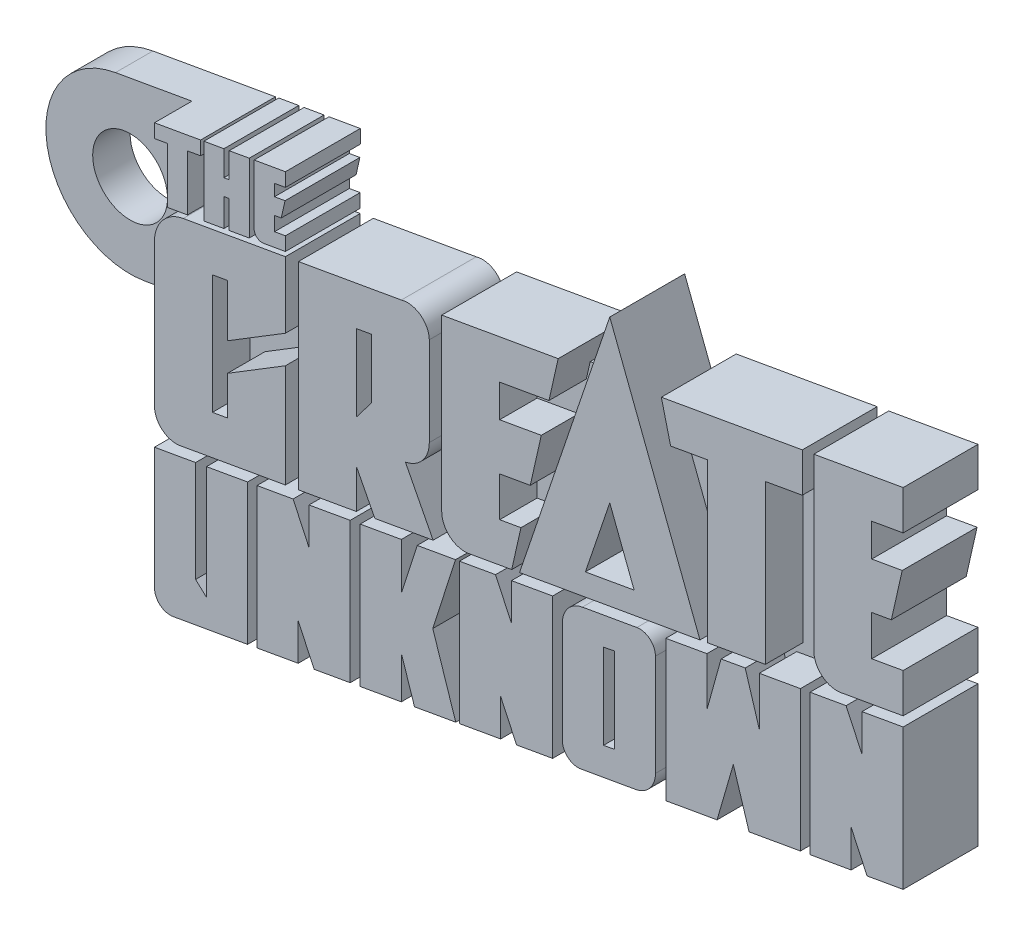
from build123d import *

# Parameters (mm, degrees)
BOSS_EXTRUDE1_DEPTH    = 2
BOSS_EXTRUDE1_2_DEPTH  = 2
BOSS_EXTRUDE1_3_DEPTH  = 2
BOSS_EXTRUDE1_4_DEPTH  = 2
BOSS_EXTRUDE1_5_DEPTH  = 2
BOSS_EXTRUDE1_6_DEPTH  = 2
BOSS_EXTRUDE1_7_DEPTH  = 2
BOSS_EXTRUDE1_8_DEPTH  = 2
BOSS_EXTRUDE1_9_DEPTH  = 2
BOSS_EXTRUDE1_10_DEPTH = 2
BOSS_EXTRUDE1_11_DEPTH = 2
BOSS_EXTRUDE1_12_DEPTH = 2
BOSS_EXTRUDE1_13_DEPTH = 2
BOSS_EXTRUDE1_14_DEPTH = 2
BOSS_EXTRUDE1_15_DEPTH = 2
BOSS_EXTRUDE1_16_DEPTH = 2
SKETCH3_R              = 2
BOSS_EXTRUDE2_DEPTH    = 2


with BuildPart() as part:
    # Sketch1 → Boss-Extrude1 (new body)
    with BuildSketch(Plane.XY):
        with BuildLine():
            Line((8.52687857, 18.63088909), (8.52687857, 11.115073474))
            Line((8.52687857, 11.115073474), (4.54411302, 10.41280445))
            ThreePointArc((4.54411302, 10.41280445), (3.854578969, 10.597564542), (3.552889466, 11.244539768))
            Line((3.552889466, 11.244539768), (3.552889466, 17.753840609))
            Line((3.552889466, 17.753840609), (5.74780863, 18.140864079))
            Line((5.74780863, 18.140864079), (5.74780863, 12.731665884))
            Line((5.74780863, 12.731665884), (6.331959407, 12.196171059))
            Line((6.331959407, 12.196171059), (6.331959407, 18.243865621))
            Line((6.331959407, 18.243865621), (8.52687857, 18.63088909))
        make_face()
    extrude(amount=BOSS_EXTRUDE1_DEPTH)



with BuildPart() as body_2:
    # Sketch1 → Boss-Extrude1 2 (new body)
    with BuildSketch(Plane.XY):
        Polygon((14.007807054, 12.081509045), (14.007807054, 19.597324661), (11.810238392, 19.209834014), (11.810238392, 17.233228675), (10.95855946, 19.05966004), (9.032205584, 18.719991877), (9.032205584, 11.204176261), (11.229774246, 11.591666908), (11.229774246, 13.568272247), (12.081453179, 11.741840883), align=None)
    extrude(amount=BOSS_EXTRUDE1_2_DEPTH)


with BuildPart() as body_3:
    # Sketch1 → Boss-Extrude1 3 (new body)
    with BuildSketch(Plane.XY):
        Polygon((18.421679589, 16.7977552), (19.635469359, 20.589633364), (17.58977616, 20.228922459), (16.741666195, 17.579427683), (16.741666195, 20.079377789), (14.544097534, 19.691887142), (14.544097534, 12.176071526), (16.741666195, 12.563562173), (16.741666195, 14.819854568), (17.444797063, 12.687543116), (19.648870789, 13.076180782), align=None)
    extrude(amount=BOSS_EXTRUDE1_3_DEPTH)


with BuildPart() as body_4:
    # Sketch1 → Boss-Extrude1 4 (new body)
    with BuildSketch(Plane.XY):
        Polygon((24.824497174, 13.988783355), (24.824497174, 21.504598971), (22.626928512, 21.117108324), (22.626928512, 19.140502985), (21.775249579, 20.96693435), (19.848895703, 20.627266187), (19.848895703, 13.111450571), (22.046464365, 13.498941218), (22.046464365, 15.475546557), (22.898143298, 13.649115193), align=None)
    extrude(amount=BOSS_EXTRUDE1_4_DEPTH)


with BuildPart() as body_5:
    # Sketch1 → Boss-Extrude1 5 (new body)
    with BuildSketch(Plane.XY):
        with BuildLine():
            Line((30.319466901, 16.043250778), (30.319466901, 21.466995618))
            ThreePointArc((30.319466901, 21.466995618), (30.017777399, 22.113970844), (29.328243348, 22.298730936))
            Line((29.328243348, 22.298730936), (26.412887063, 21.784674965))
            ThreePointArc((26.412887063, 21.784674965), (25.646494971, 21.342198284), (25.343823096, 20.510614141))
            Line((25.343823096, 20.510614141), (25.343823096, 15.086869302))
            ThreePointArc((25.343823096, 15.086869302), (25.645512598, 14.439894076), (26.335046649, 14.255133983))
            Line((26.335046649, 14.255133983), (29.250402934, 14.769189955))
            ThreePointArc((29.250402934, 14.769189955), (30.016795026, 15.211666635), (30.319466901, 16.043250778))
        make_face()
        Polygon((27.538848883, 20.496386478), (27.538848883, 15.948276814), (28.124441114, 16.06368579), (28.124441114, 20.611795454), align=None, mode=Mode.SUBTRACT)
    extrude(amount=BOSS_EXTRUDE1_5_DEPTH)


with BuildPart() as body_6:
    # Sketch1 → Boss-Extrude1 6 (new body)
    with BuildSketch(Plane.XY):
        Polygon((35.114199923, 23.318951189), (35.866848098, 20.857149935), (35.866848098, 23.45166337), (38.064598893, 23.839186132), (38.064598893, 16.323370516), (35.322075727, 15.839789686), (34.479157896, 18.537006513), (33.611442684, 15.538158927), (30.871044547, 15.054952797), (30.871044547, 22.570768413), (33.068795343, 22.958291176), (33.068795343, 20.363777741), (33.825311065, 23.091685309), align=None)
    extrude(amount=BOSS_EXTRUDE1_6_DEPTH)


with BuildPart() as body_7:
    # Sketch1 → Boss-Extrude1 7 (new body)
    with BuildSketch(Plane.XY):
        Polygon((38.577229676, 16.413761154), (38.577229676, 23.92957677), (40.503583552, 24.269244933), (41.355262485, 22.442813568), (41.355262485, 24.419418907), (43.552831147, 24.806909554), (43.552831147, 17.291093938), (41.626477271, 16.951425776), (40.774798338, 18.777857141), (40.774798338, 16.801251801), align=None)
    extrude(amount=BOSS_EXTRUDE1_7_DEPTH)


with BuildPart() as body_8:
    # Sketch1 → Boss-Extrude1 8 (new body)
    with BuildSketch(Plane.XY):
        with BuildLine():
            Line((38.781950694, 35.04479555), (38.781950694, 25.945686336))
            ThreePointArc((38.781950694, 25.945686336), (39.221354228, 25.003382415), (40.225644058, 24.734283766))
            Line((40.225644058, 24.734283766), (43.552831147, 25.32095662))
            Line((43.552831147, 25.32095662), (43.552831147, 27.420458771))
            Line((43.552831147, 27.420458771), (41.875683739, 27.124732432))
            Line((41.875683739, 27.124732432), (41.875683739, 29.266910955))
            Line((41.875683739, 29.266910955), (42.922867379, 29.451557685))
            Line((42.922867379, 29.451557685), (43.503747496, 32.02562888))
            Line((43.503747496, 32.02562888), (41.875683739, 31.738557313))
            Line((41.875683739, 31.738557313), (41.875683739, 33.490802006))
            Line((41.875683739, 33.490802006), (43.552831147, 33.786528344))
            Line((43.552831147, 33.786528344), (43.552831147, 35.886030495))
            Line((43.552831147, 35.886030495), (38.781950694, 35.04479555))
        make_face()
    extrude(amount=BOSS_EXTRUDE1_8_DEPTH)


with BuildPart() as body_9:
    # Sketch1 → Boss-Extrude1 9 (new body)
    with BuildSketch(Plane.XY):
        Polygon((33.096005404, 23.477136109), (33.096005404, 31.942707833), (31.129648429, 31.595986045), (30.633795623, 33.608055968), (38.164930616, 34.935998262), (38.164930616, 32.836496111), (36.189738449, 32.48821644), (36.189738449, 24.022644716), align=None)
    extrude(amount=BOSS_EXTRUDE1_9_DEPTH)


with BuildPart() as body_10:
    # Sketch1 → Boss-Extrude1 10 (new body)
    with BuildSketch(Plane.XY):
        Polygon((27.878062603, 35.939645782), (23.05734626, 21.707049652), (32.697500329, 23.406868912), align=None)
        Polygon((26.574970713, 23.494534583), (27.878062603, 27.341759618), (29.18080887, 23.954014158), align=None, mode=Mode.SUBTRACT)
    extrude(amount=BOSS_EXTRUDE1_10_DEPTH)


with BuildPart() as body_11:
    # Sketch1 → Boss-Extrude1 11 (new body)
    with BuildSketch(Plane.XY):
        with BuildLine():
            Line((18.900929672, 22.440125926), (18.900929672, 31.53923514))
            Line((18.900929672, 31.53923514), (25.121821984, 32.636146298))
            Line((25.121821984, 32.636146298), (24.628402264, 30.449640938))
            Line((24.628402264, 30.449640938), (21.994662717, 29.985241596))
            Line((21.994662717, 29.985241596), (21.994662717, 28.244598362))
            Line((21.994662717, 28.244598362), (24.219320665, 28.636865581))
            Line((24.219320665, 28.636865581), (23.630414894, 26.027230067))
            Line((23.630414894, 26.027230067), (21.994662717, 25.738802824))
            Line((21.994662717, 25.738802824), (21.994662717, 23.619172022))
            Line((21.994662717, 23.619172022), (23.132264589, 23.819761926))
            Line((23.132264589, 23.819761926), (22.63884487, 21.633256565))
            Line((22.63884487, 21.633256565), (21.994662717, 21.519669871))
            Line((21.994662717, 21.519669871), (20.344623037, 21.228723356))
            ThreePointArc((20.344623037, 21.228723356), (19.340333207, 21.497822005), (18.900929672, 22.440125926))
        make_face()
    extrude(amount=BOSS_EXTRUDE1_11_DEPTH)


with BuildPart() as body_12:
    # Sketch1 → Boss-Extrude1 12 (new body)
    with BuildSketch(Plane.XY):
        with BuildLine():
            Line((11.242596723, 30.188864413), (11.242596723, 19.623790538))
            Line((11.242596723, 19.623790538), (14.336329768, 20.169299145))
            Line((14.336329768, 20.169299145), (14.336329768, 22.268801296))
            Line((14.336329768, 22.268801296), (15.327888253, 20.344137659))
            Line((15.327888253, 20.344137659), (18.440327612, 20.892944694))
            Line((18.440327612, 20.892944694), (16.95766904, 23.77085768))
            ThreePointArc((16.95766904, 23.77085768), (17.875172194, 24.309957917), (18.236591537, 25.310866084))
            Line((18.236591537, 25.310866084), (18.236591537, 30.066171591))
            ThreePointArc((18.236591537, 30.066171591), (17.758194048, 30.980569497), (16.741666195, 31.15849873))
            Line((16.741666195, 31.15849873), (11.242596723, 30.188864413))
        make_face()
        Polygon((15.142858492, 28.777083644), (15.142858492, 25.594048857), (14.336329768, 24.535055064), (14.336329768, 28.634870869), align=None, mode=Mode.SUBTRACT)
    extrude(amount=BOSS_EXTRUDE1_12_DEPTH)


with BuildPart() as body_13:
    # Sketch1 → Boss-Extrude1 13 (new body)
    with BuildSketch(Plane.XY):
        with BuildLine():
            Line((8.876161495, 33.704167488), (8.876161495, 30.52341899))
            ThreePointArc((8.876161495, 30.52341899), (9.029827084, 30.193882073), (9.381041344, 30.099774495))
            Line((9.381041344, 30.099774495), (10.546771151, 30.305324112))
            Line((10.546771151, 30.305324112), (10.546771151, 31.032471608))
            Line((10.546771151, 31.032471608), (9.964533452, 30.929807392))
            Line((9.964533452, 30.929807392), (9.964533452, 31.682526065))
            Line((9.964533452, 31.682526065), (10.32486341, 31.746061958))
            Line((10.32486341, 31.746061958), (10.52831433, 32.647620022))
            Line((10.52831433, 32.647620022), (9.964533452, 32.548210242))
            Line((9.964533452, 32.548210242), (9.964533452, 33.168929334))
            Line((9.964533452, 33.168929334), (10.548723852, 33.271937863))
            Line((10.548723852, 33.271937863), (10.548723852, 33.999085359))
            Line((10.548723852, 33.999085359), (8.876161495, 33.704167488))
        make_face()
    extrude(amount=BOSS_EXTRUDE1_13_DEPTH)


with BuildPart() as body_14:
    # Sketch1 → Boss-Extrude1 14 (new body)
    with BuildSketch(Plane.XY):
        Polygon((6.19251459, 33.230968132), (6.19251459, 29.5375512), (7.262626263, 29.72624076), (7.262626263, 31.20577456), (7.546221103, 31.255779982), (7.546221103, 29.776246182), (8.616332776, 29.964935742), (8.616332776, 33.658352675), (7.546221103, 33.469663114), (7.546221103, 32.128022483), (7.262626263, 32.078017061), (7.262626263, 33.419657692), align=None)
    extrude(amount=BOSS_EXTRUDE1_14_DEPTH)


with BuildPart() as body_15:
    # Sketch1 → Boss-Extrude1 15 (new body)
    with BuildSketch(Plane.XY):
        Polygon((4.250137104, 32.156949171), (4.250137104, 29.195057642), (5.320248777, 29.383747203), (5.320248777, 32.345638731), (6.016841446, 32.468466813), (6.016841446, 33.199992217), (3.552889466, 32.765531004), (3.552889466, 32.0340056), align=None)
    extrude(amount=BOSS_EXTRUDE1_15_DEPTH)


with BuildPart() as body_16:
    # Sketch1 → Boss-Extrude1 16 (new body)
    with BuildSketch(Plane.XY):
        with BuildLine():
            Line((3.552889466, 19.659368163), (3.552889466, 27.275452938))
            ThreePointArc((3.552889466, 27.275452938), (3.98714993, 28.468573755), (5.086736023, 29.103420083))
            Line((5.086736023, 29.103420083), (10.546771151, 30.066171591))
            Line((10.546771151, 30.066171591), (10.546771151, 26.523544535))
            Line((10.546771151, 26.523544535), (7.453038106, 24.627702486))
            Line((7.453038106, 24.627702486), (7.453038106, 27.421160833))
            Line((7.453038106, 27.421160833), (6.646622512, 27.278968006))
            Line((6.646622512, 27.278968006), (6.646622512, 20.912898433))
            Line((6.646622512, 20.912898433), (7.453038106, 21.05509126))
            Line((7.453038106, 21.05509126), (7.453038106, 23.122472288))
            Line((7.453038106, 23.122472288), (10.546771151, 25.018314336))
            Line((10.546771151, 25.018314336), (10.546771151, 19.501097716))
            Line((10.546771151, 19.501097716), (4.92323024, 18.509515726))
            ThreePointArc((4.92323024, 18.509515726), (3.969967354, 18.764941746), (3.552889466, 19.659368163))
        make_face()
    extrude(amount=BOSS_EXTRUDE1_16_DEPTH)


with BuildPart() as part_1:
    add(part.part)

    add(body_2.part)  # Boss-Extrude2 merges body 2

    add(body_3.part)  # Boss-Extrude2 merges body 3

    add(body_4.part)  # Boss-Extrude2 merges body 4

    add(body_5.part)  # Boss-Extrude2 merges body 5

    add(body_6.part)  # Boss-Extrude2 merges body 6

    add(body_7.part)  # Boss-Extrude2 merges body 7

    add(body_8.part)  # Boss-Extrude2 merges body 8

    add(body_9.part)  # Boss-Extrude2 merges body 9

    add(body_10.part)  # Boss-Extrude2 merges body 10

    add(body_11.part)  # Boss-Extrude2 merges body 11

    add(body_12.part)  # Boss-Extrude2 merges body 12

    add(body_13.part)  # Boss-Extrude2 merges body 13

    add(body_14.part)  # Boss-Extrude2 merges body 14

    add(body_15.part)  # Boss-Extrude2 merges body 15

    add(body_16.part)  # Boss-Extrude2 merges body 16
    # Sketch3 → Boss-Extrude2 (add)
    with BuildSketch(Plane(origin=(0, 0, 0), x_dir=(-1, 0, 0), z_dir=(0, 0, -1))):
        with BuildLine():
            Line((-7.262626263, 32.884601856), (-7.546221103, 32.934607278))
            Line((-7.546221103, 32.934607278), (-7.546221103, 33.469663114))
            Line((-7.546221103, 33.469663114), (-8.616332776, 33.658352675))
            Line((-8.616332776, 33.658352675), (-8.616332776, 33.123296838))
            Line((-8.616332776, 33.123296838), (-8.876161495, 33.169111652))
            Line((-8.876161495, 33.169111652), (-8.876161495, 33.704167488))
            Line((-8.876161495, 33.704167488), (-10.548723852, 33.999085359))
            Line((-10.548723852, 33.999085359), (-10.548723852, 33.271937863))
            Line((-10.548723852, 33.271937863), (-9.964533452, 33.168929334))
            Line((-9.964533452, 33.168929334), (-9.964533452, 32.548210242))
            Line((-9.964533452, 32.548210242), (-10.52831433, 32.647620022))
            Line((-10.52831433, 32.647620022), (-10.32486341, 31.746061958))
            Line((-10.32486341, 31.746061958), (-9.964533452, 31.682526065))
            Line((-9.964533452, 31.682526065), (-9.964533452, 30.929807392))
            Line((-9.964533452, 30.929807392), (-10.546771151, 31.032471608))
            Line((-10.546771151, 31.032471608), (-10.546771151, 30.305324112))
            Line((-10.546771151, 30.305324112), (-9.964533452, 30.202659897))
            Line((-9.964533452, 30.202659897), (-9.964533452, 29.963507376))
            Line((-9.964533452, 29.963507376), (-10.546771151, 30.066171591))
            Line((-10.546771151, 30.066171591), (-10.546771151, 28.833868117))
            Line((-10.546771151, 28.833868117), (-11.242596723, 28.956560939))
            Line((-11.242596723, 28.956560939), (-11.242596723, 30.188864413))
            Line((-11.242596723, 30.188864413), (-16.741666195, 31.15849873))
            ThreePointArc((-16.741666195, 31.15849873), (-17.707863765, 31.01535989), (-18.227220402, 30.188138544))
            Line((-18.227220402, 30.188138544), (-18.900929672, 30.306931665))
            Line((-18.900929672, 30.306931665), (-18.900929672, 31.53923514))
            Line((-18.900929672, 31.53923514), (-25.121821984, 32.636146298))
            Line((-25.121821984, 32.636146298), (-24.832209118, 31.352776262))
            Line((-24.832209118, 31.352776262), (-26.419228628, 31.63261062))
            Line((-26.419228628, 31.63261062), (-27.878062603, 35.939645782))
            Line((-27.878062603, 35.939645782), (-29.336509647, 32.147005974))
            Line((-29.336509647, 32.147005974), (-30.92483659, 32.427070868))
            Line((-30.92483659, 32.427070868), (-30.633795623, 33.608055968))
            Line((-30.633795623, 33.608055968), (-38.164930616, 34.935998262))
            Line((-38.164930616, 34.935998262), (-38.164930616, 33.703694788))
            Line((-38.164930616, 33.703694788), (-38.781950694, 33.812492075))
            Line((-38.781950694, 33.812492075), (-38.781950694, 35.04479555))
            Line((-38.781950694, 35.04479555), (-43.552831147, 35.886030495))
            Line((-43.552831147, 35.886030495), (-43.552831147, 33.786528344))
            Line((-43.552831147, 33.786528344), (-41.875683739, 33.490802006))
            Line((-41.875683739, 33.490802006), (-41.875683739, 31.738557313))
            Line((-41.875683739, 31.738557313), (-43.503747496, 32.02562888))
            Line((-43.503747496, 32.02562888), (-42.922867379, 29.451557685))
            Line((-42.922867379, 29.451557685), (-41.875683739, 29.266910955))
            Line((-41.875683739, 29.266910955), (-41.875683739, 27.124732432))
            Line((-41.875683739, 27.124732432), (-43.552831147, 27.420458771))
            Line((-43.552831147, 27.420458771), (-43.552831147, 25.32095662))
            Line((-43.552831147, 25.32095662), (-41.875683739, 25.025230281))
            Line((-41.875683739, 25.025230281), (-41.875683739, 24.511183216))
            Line((-41.875683739, 24.511183216), (-43.552831147, 24.806909554))
            Line((-43.552831147, 24.806909554), (-43.552831147, 17.291093938))
            Line((-43.552831147, 17.291093938), (-41.626477271, 16.951425776))
            Line((-41.626477271, 16.951425776), (-40.774798338, 18.777857141))
            Line((-40.774798338, 18.777857141), (-40.774798338, 16.801251801))
            Line((-40.774798338, 16.801251801), (-38.577229676, 16.413761154))
            Line((-38.577229676, 16.413761154), (-38.577229676, 17.646064628))
            Line((-38.577229676, 17.646064628), (-38.064598893, 17.55567399))
            Line((-38.064598893, 17.55567399), (-38.064598893, 16.323370516))
            Line((-38.064598893, 16.323370516), (-35.322075727, 15.839789686))
            Line((-35.322075727, 15.839789686), (-34.479157896, 18.537006513))
            Line((-34.479157896, 18.537006513), (-33.611442684, 15.538158927))
            Line((-33.611442684, 15.538158927), (-30.871044547, 15.054952797))
            Line((-30.871044547, 15.054952797), (-30.871044547, 16.287256271))
            Line((-30.871044547, 16.287256271), (-30.319466901, 16.189998251))
            Line((-30.319466901, 16.189998251), (-30.319466901, 16.043250778))
            ThreePointArc((-30.319466901, 16.043250778), (-30.016795026, 15.211666635), (-29.250402934, 14.769189955))
            Line((-29.250402934, 14.769189955), (-26.335046649, 14.255133983))
            ThreePointArc((-26.335046649, 14.255133983), (-25.645512598, 14.439894076), (-25.343823096, 15.086869302))
            Line((-25.343823096, 15.086869302), (-25.343823096, 15.312658001))
            Line((-25.343823096, 15.312658001), (-24.824497174, 15.221086829))
            Line((-24.824497174, 15.221086829), (-24.824497174, 13.988783355))
            Line((-24.824497174, 13.988783355), (-22.898143298, 13.649115193))
            Line((-22.898143298, 13.649115193), (-22.046464365, 15.475546557))
            Line((-22.046464365, 15.475546557), (-22.046464365, 13.498941218))
            Line((-22.046464365, 13.498941218), (-19.848895703, 13.111450571))
            Line((-19.848895703, 13.111450571), (-19.848895703, 14.343754045))
            Line((-19.848895703, 14.343754045), (-19.264846709, 14.240770449))
            Line((-19.264846709, 14.240770449), (-19.648870789, 13.076180782))
            Line((-19.648870789, 13.076180782), (-17.444797063, 12.687543116))
            Line((-17.444797063, 12.687543116), (-16.741666195, 14.819854568))
            Line((-16.741666195, 14.819854568), (-16.741666195, 12.563562173))
            Line((-16.741666195, 12.563562173), (-14.544097534, 12.176071526))
            Line((-14.544097534, 12.176071526), (-14.544097534, 13.408375))
            Line((-14.544097534, 13.408375), (-14.007807054, 13.313812519))
            Line((-14.007807054, 13.313812519), (-14.007807054, 12.081509045))
            Line((-14.007807054, 12.081509045), (-12.081453179, 11.741840883))
            Line((-12.081453179, 11.741840883), (-11.229774246, 13.568272247))
            Line((-11.229774246, 13.568272247), (-11.229774246, 11.591666908))
            Line((-11.229774246, 11.591666908), (-9.032205584, 11.204176261))
            Line((-9.032205584, 11.204176261), (-9.032205584, 12.436479735))
            Line((-9.032205584, 12.436479735), (-8.52687857, 12.347376948))
            Line((-8.52687857, 12.347376948), (-8.52687857, 11.115073474))
            Line((-8.52687857, 11.115073474), (-4.54411302, 10.41280445))
            ThreePointArc((-4.54411302, 10.41280445), (-3.854578969, 10.597564542), (-3.552889466, 11.244539768))
            Line((-3.552889466, 11.244539768), (-3.552889466, 17.753840609))
            Line((-3.552889466, 17.753840609), (-4.785192941, 17.97112896))
            Line((-4.785192941, 17.97112896), (-4.785192941, 18.493572101))
            ThreePointArc((-4.785192941, 18.493572101), (-3.918074401, 18.811185944), (-3.552889466, 19.659368163))
            Line((-3.552889466, 19.659368163), (-3.552889466, 23.626691497))
            Line((-3.552889466, 23.626691497), (-1.031553904, 23.18211201))
            ThreePointArc((-1.031553904, 23.18211201), (4.181497784, 26.832330099), (0.531279695, 32.045381787))
            Line((0.531279695, 32.045381787), (-3.552889466, 32.765531004))
            Line((-3.552889466, 32.765531004), (-6.016841446, 33.199992217))
            Line((-6.016841446, 33.199992217), (-6.016841446, 32.664936381))
            Line((-6.016841446, 32.664936381), (-6.19251459, 32.695912296))
            Line((-6.19251459, 32.695912296), (-6.19251459, 33.230968132))
            Line((-6.19251459, 33.230968132), (-7.262626263, 33.419657692))
            Line((-7.262626263, 33.419657692), (-7.262626263, 32.884601856))
        make_face()
        with Locations((-0.250137104, 27.613746898)):
            Circle(SKETCH3_R, mode=Mode.SUBTRACT)
    extrude(amount=BOSS_EXTRUDE2_DEPTH)


solid = part_1.part
